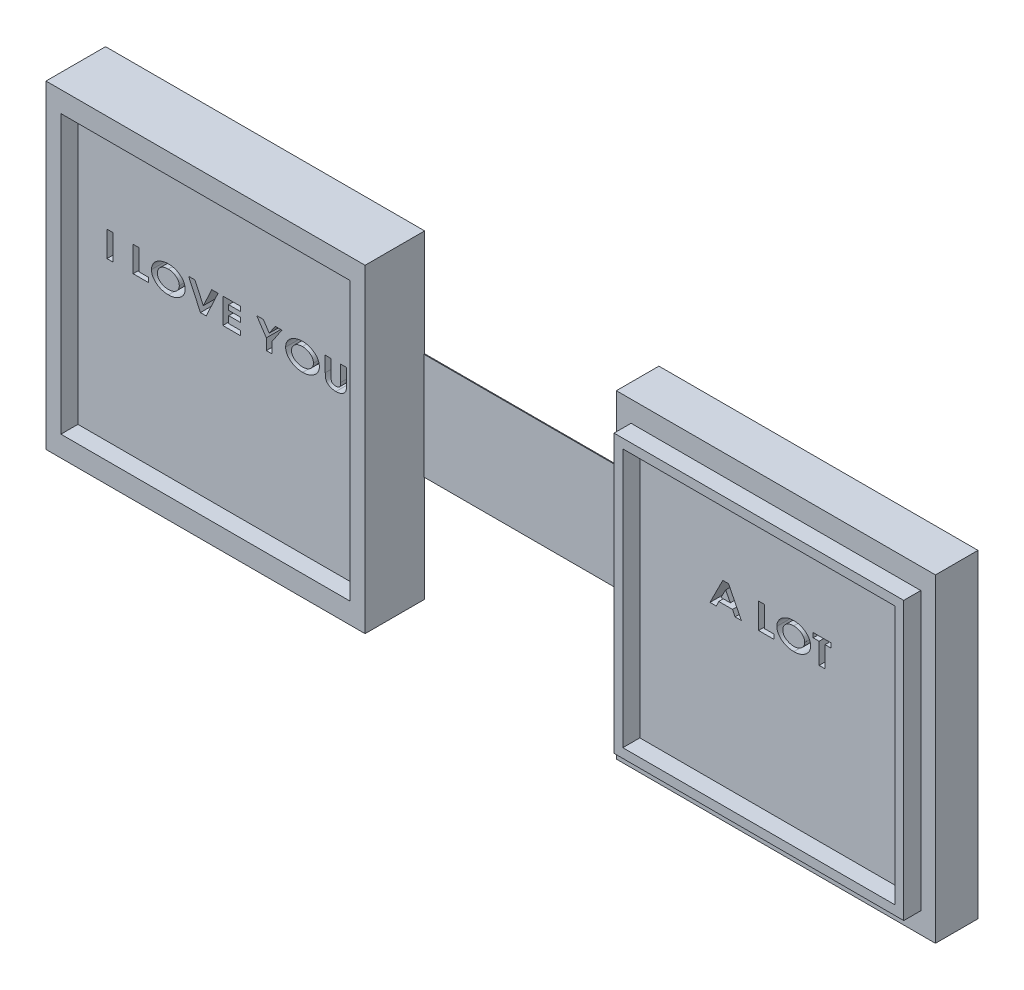
from build123d import *

# Parameters (mm, degrees)
BOSS_EXTRUDE1_DEPTH   = 10
BOSS_EXTRUDE1_2_DEPTH = 10
SKETCH2_3_W           = 55.063291139
SKETCH2_3_H           = 25
BOSS_EXTRUDE2_DEPTH   = 0.2
BOSS_EXTRUDE3_DEPTH   = 4
BOSS_EXTRUDE4_DEPTH   = 4
SKETCH8_W             = 1.384615385
SKETCH8_H             = 6
CUT_EXTRUDE2_DEPTH    = 7


with BuildPart() as part:
    # Sketch2 → Boss-Extrude1 (new body)
    with BuildSketch(Plane.XY):
        Polygon((-12.49990942, -20.310872493), (-12.49990942, -45.310872493), (-87.49990942, -45.310872493), (-87.49990942, 29.689127507), (-12.49990942, 29.689127507), (-12.49990942, 4.689127507), align=None)
    extrude(amount=BOSS_EXTRUDE1_DEPTH)



with BuildPart() as body_2:
    # Sketch2 → Boss-Extrude1 2 (new body)
    with BuildSketch(Plane.XY):
        Polygon((42.563381719, 4.689127507), (42.563381719, -20.310872493), (42.563381719, -45.310872493), (117.563381719, -45.310872493), (117.563381719, 29.689127507), (42.563381719, 29.689127507), align=None)
    extrude(amount=BOSS_EXTRUDE1_2_DEPTH)


with BuildPart() as part_1:
    add(part.part)

    add(body_2.part)  # Boss-Extrude2 merges body 2
    # Sketch2_3 → Boss-Extrude2 (add)
    with BuildSketch(Plane.XY):
        with Locations((15.03173615, -7.810872493)):
            Rectangle(SKETCH2_3_W, SKETCH2_3_H)
    extrude(amount=BOSS_EXTRUDE2_DEPTH)

    # Sketch5 → Boss-Extrude3 (add)
    with BuildSketch(Plane.XY.offset(10)):
        Polygon((-83.991546919, 24.821747046), (-16.008271922, 24.821747046), (-12.49990942, 29.689127507), (-87.49990942, 29.689127507), align=None)
        Polygon((-16.008271922, 24.821747046), (-16.008271922, -40.443492031), (-12.49990942, -45.310872493), (-12.49990942, 29.689127507), align=None)
        Polygon((-16.008271922, -40.443492031), (-12.49990942, -45.310872493), (-87.49990942, -45.310872493), (-87.49990942, 29.689127507), (-83.991546919, 24.821747046), (-83.991546919, -40.443492031), align=None)
    extrude(amount=BOSS_EXTRUDE3_DEPTH)

    # Sketch6 → Boss-Extrude4 (add)
    with BuildSketch(Plane.XY.offset(10)):
        Polygon((114.10947308, 24.782956382), (112.046327266, 22.605014842), (48.080436172, 22.605014842), (46.017290358, 24.782956382), align=None)
        Polygon((114.10947308, -40.404701367), (112.046327266, -38.226759827), (112.046327266, 22.605014842), (114.10947308, 24.782956382), align=None)
        Polygon((46.017290358, -40.404701367), (114.10947308, -40.404701367), (112.046327266, -38.226759827), (48.080436172, -38.226759827), (48.080436172, 22.605014842), (46.017290358, 24.782956382), align=None)
    extrude(amount=BOSS_EXTRUDE4_DEPTH)

    # Sketch8 → Cut-Extrude2 (cut)
    with BuildSketch(Plane.XY.offset(10)):
        with Locations((-76.480051234, -0.292779357)):
            Rectangle(SKETCH8_W, SKETCH8_H)
        Polygon((-71.018512773, 2.707220643), (-69.633897389, 2.707220643), (-69.633897389, -2.21585628), (-67.403128158, -2.21585628), (-67.403128158, -3.292779357), (-71.018512773, -3.292779357), align=None)
        with BuildLine():
            add(Edge.make_bspline(
                [(-62.733657004, 2.861066797), (-62.600922093, 2.858406668), (-62.339935127, 2.85317625), (-61.955697879, 2.808562096), (-61.585428768, 2.736832123), (-61.228959719, 2.636061047), (-60.887086087, 2.505697363), (-60.559861681, 2.346100222), (-60.246421792, 2.158141413), (-59.999306765, 1.978433493), (-59.811863981, 1.8233402), (-59.679959104, 1.703376976), (-59.556214435, 1.580379342), (-59.443142799, 1.45325819), (-59.336986998, 1.324393321), (-59.242733923, 1.190620751), (-59.156024227, 1.054708376), (-59.076830549, 0.916145229), (-59.009279244, 0.773509087), (-58.949170347, 0.628227538), (-58.900683399, 0.479253805), (-58.859472962, 0.327272656), (-58.826907017, 0.172430625), (-58.804045187, 0.014274117), (-58.79077044, -0.147117298), (-58.788758948, -0.25589632), (-58.787743542, -0.310808203)],
                knots=[0, 0, 0, 0, 1.701621513, 3.345774183, 4.952818867, 6.533559192, 8.08973942, 9.638370861, 11.196102205, 12.770417818, 13.551212677, 14.314953304, 15.05603302, 15.787307124, 16.495794601, 17.195736741, 17.884100935, 18.562753464, 19.240627723, 19.906540461, 20.577507338, 21.247982325, 21.925077417, 22.605128591, 23.295865934, 24, 24, 24, 24], degree=3))
            add(Edge.make_bspline(
                [(-58.787743542, -0.310808203), (-58.78877522, -0.3649174), (-58.790826313, -0.472492723), (-58.803962694, -0.632303529), (-58.827194238, -0.789112534), (-58.858314866, -0.942823265), (-58.897736737, -1.093549743), (-58.947390433, -1.24081721), (-59.006344314, -1.384765866), (-59.07374232, -1.525643336), (-59.149870345, -1.66336771), (-59.235026036, -1.798068499), (-59.330694622, -1.928989316), (-59.433842993, -2.057615845), (-59.545811508, -2.183171807), (-59.667901241, -2.304159607), (-59.797479712, -2.423721553), (-59.982938286, -2.576388055), (-60.227755411, -2.753496139), (-60.5387143, -2.939618947), (-60.865839219, -3.095776156), (-61.207332529, -3.22531263), (-61.564595072, -3.325061823), (-61.937313099, -3.395568523), (-62.325204993, -3.43833209), (-62.588916502, -3.44383229), (-62.722839696, -3.446625511)],
                knots=[0, 0, 0, 0, 0.697386028, 1.386483854, 2.064877695, 2.739310107, 3.406868283, 4.071444263, 4.740737576, 5.410508757, 6.083060732, 6.767791916, 7.46289943, 8.171737429, 8.892141444, 9.629680956, 10.386190422, 11.163678676, 12.724354505, 14.275829196, 15.827827946, 17.390074696, 18.977437917, 20.601801155, 22.274259438, 24, 24, 24, 24], degree=3))
            add(Edge.make_bspline(
                [(-62.722839696, -3.446625511), (-62.862798511, -3.444113121), (-63.13783885, -3.439175895), (-63.540667989, -3.39273309), (-63.926411388, -3.322594957), (-64.292606603, -3.217784133), (-64.642076275, -3.087462333), (-64.972558186, -2.925370831), (-65.285270981, -2.734813458), (-65.529021878, -2.552791621), (-65.712036458, -2.395668565), (-65.840423925, -2.274184025), (-65.960844737, -2.150738619), (-66.072013386, -2.023978012), (-66.173921474, -1.894112561), (-66.268131122, -1.762206586), (-66.352118182, -1.626962047), (-66.428692789, -1.489912998), (-66.494354874, -1.348948167), (-66.552194047, -1.205747145), (-66.601912407, -1.060278811), (-66.641347618, -0.911575844), (-66.672991427, -0.760395679), (-66.694090269, -0.606143935), (-66.707898909, -0.449279737), (-66.70984024, -0.343690253), (-66.710820466, -0.290375511)],
                knots=[0, 0, 0, 0, 1.784004293, 3.505839534, 5.164104166, 6.778110649, 8.356058462, 9.914283128, 11.464219954, 13.019326122, 13.787338316, 14.539035367, 15.272437815, 15.985633446, 16.68776482, 17.376668663, 18.051409406, 18.716821711, 19.377293231, 20.032826539, 20.685506957, 21.336104687, 21.993367612, 22.653720573, 23.320230207, 24, 24, 24, 24], degree=3))
            add(Edge.make_bspline(
                [(-66.710820466, -0.290375511), (-66.709248595, -0.219381645), (-66.706121498, -0.078145662), (-66.679620908, 0.131148243), (-66.639379845, 0.336327408), (-66.581010038, 0.536824964), (-66.506618956, 0.733155715), (-66.414204528, 0.924655488), (-66.30752088, 1.112854932), (-66.183044911, 1.29483208), (-66.046179778, 1.471426129), (-65.893255335, 1.636720747), (-65.731154375, 1.795892196), (-65.554008476, 1.942637687), (-65.365570498, 2.081728276), (-65.165213763, 2.211603084), (-64.951349596, 2.330261099), (-64.72759824, 2.440336532), (-64.495740751, 2.54027601), (-64.256810071, 2.624878227), (-64.014178327, 2.699309744), (-63.766118226, 2.75699729), (-63.514528187, 2.805212202), (-63.257885046, 2.836304814), (-62.997264161, 2.858347384), (-62.821845581, 2.86015703), (-62.733657004, 2.861066797)],
                knots=[0, 0, 0, 0, 0.908646913, 1.807672237, 2.696971879, 3.583367145, 4.47793267, 5.381919862, 6.30320595, 7.245054832, 8.2024345, 9.160995254, 10.125930706, 11.10912711, 12.103275238, 13.123444517, 14.16375238, 15.23278865, 16.315180442, 17.394163501, 18.476555293, 19.562732787, 20.653322387, 21.754667852, 22.871199116, 24, 24, 24, 24], degree=3))
        make_face()
        with BuildLine():
            add(Edge.make_bspline(
                [(-62.754089696, 1.78414372), (-62.843108459, 1.782289357), (-63.017977885, 1.778646627), (-63.274695453, 1.750198317), (-63.520924047, 1.705324302), (-63.756004226, 1.639929692), (-63.980201447, 1.557233185), (-64.19348302, 1.455522029), (-64.395648993, 1.334939374), (-64.58572423, 1.197650172), (-64.759109305, 1.046663287), (-64.911078665, 0.883385075), (-65.03866924, 0.709606685), (-65.145120706, 0.526906627), (-65.225919007, 0.33271736), (-65.283244487, 0.128917807), (-65.319443572, -0.08477018), (-65.323922926, -0.230534263), (-65.326205081, -0.304798587)],
                knots=[0, 0, 0, 0, 1.156256363, 2.271362584, 3.351443693, 4.404613939, 5.437209731, 6.452274934, 7.469899128, 8.491270218, 9.494550198, 10.452182295, 11.382870607, 12.289942592, 13.192808459, 14.107242739, 15.035672325, 16, 16, 16, 16], degree=3))
            add(Edge.make_bspline(
                [(-65.326205081, -0.304798587), (-65.323676838, -0.387153105), (-65.318704955, -0.549106294), (-65.272304421, -0.784471469), (-65.200711175, -1.007395612), (-65.096808237, -1.216343499), (-64.963709904, -1.411609939), (-64.801681021, -1.593593644), (-64.610645817, -1.761865085), (-64.466428702, -1.858500103), (-64.39231085, -1.908163972)],
                knots=[0, 0, 0, 0, 1.015643436, 1.997300182, 2.949804991, 3.898707565, 4.867193511, 5.85870606, 6.899519615, 8, 8, 8, 8], degree=3))
            add(Edge.make_bspline(
                [(-64.39231085, -1.908163972), (-64.331143374, -1.945173034), (-64.209243503, -2.018927916), (-64.016908463, -2.112552676), (-63.818426435, -2.191950643), (-63.613183416, -2.257155964), (-63.401054158, -2.307668696), (-63.182141524, -2.343356789), (-62.956877701, -2.3656782), (-62.804622424, -2.368351105), (-62.727647389, -2.369702434)],
                knots=[0, 0, 0, 0, 0.979445747, 1.951924769, 2.927746611, 3.907192357, 4.900758842, 5.913620849, 6.945198403, 8, 8, 8, 8], degree=3))
            add(Edge.make_bspline(
                [(-62.727647389, -2.369702434), (-62.64063873, -2.367809157), (-62.469778703, -2.364091306), (-62.218460569, -2.336168585), (-61.977075188, -2.288841246), (-61.744970841, -2.224932564), (-61.523140565, -2.139705866), (-61.311342521, -2.036089743), (-61.108801936, -1.914581606), (-60.918770675, -1.775570542), (-60.744064818, -1.623974866), (-60.592334455, -1.459602246), (-60.461814056, -1.288019626), (-60.35546461, -1.106987262), (-60.272524688, -0.916609078), (-60.215561395, -0.717277011), (-60.179137548, -0.5096509), (-60.174643261, -0.368253752), (-60.172358927, -0.296385126)],
                knots=[0, 0, 0, 0, 1.14206298, 2.242683837, 3.314374117, 4.368419416, 5.39889757, 6.429147533, 7.460108749, 8.495247058, 9.51643591, 10.491510393, 11.42663233, 12.341282468, 13.241130158, 14.144903984, 15.057101202, 16, 16, 16, 16], degree=3))
            add(Edge.make_bspline(
                [(-60.172358927, -0.296385126), (-60.174712507, -0.22493402), (-60.179355783, -0.083971193), (-60.214949834, 0.123212172), (-60.274447295, 0.32147036), (-60.356225856, 0.512281184), (-60.464909178, 0.692533443), (-60.5941443, 0.866036146), (-60.748206751, 1.029934578), (-60.92396985, 1.183144687), (-61.115481673, 1.324004611), (-61.319808555, 1.446735346), (-61.533031105, 1.552633892), (-61.758176609, 1.636323704), (-61.992990136, 1.702324063), (-62.237601645, 1.750867821), (-62.492634328, 1.778457514), (-62.665883395, 1.782225384), (-62.754089696, 1.78414372)],
                knots=[0, 0, 0, 0, 0.931113683, 1.836954292, 2.730897662, 3.624474801, 4.535405159, 5.468187164, 6.440023927, 7.461466965, 8.503989252, 9.534934908, 10.564993831, 11.602940381, 12.66110933, 13.741711846, 14.85023771, 16, 16, 16, 16], degree=3))
        make_face(mode=Mode.SUBTRACT)
        Polygon((-57.980051235, 2.707220643), (-56.495676235, 2.707220643), (-54.518512773, -1.554798587), (-52.536541619, 2.707220643), (-51.056974312, 2.707220643), (-53.846637773, -3.292779357), (-55.195195466, -3.292779357), align=None)
        Polygon((-49.941589696, 2.707220643), (-45.787743542, 2.707220643), (-45.787743542, 1.630297566), (-48.556974312, 1.630297566), (-48.556974312, 0.476451413), (-45.787743542, 0.476451413), (-45.787743542, -0.600471664), (-48.556974312, -0.600471664), (-48.556974312, -2.21585628), (-45.787743542, -2.21585628), (-45.787743542, -3.292779357), (-49.941589696, -3.292779357), align=None)
        Polygon((-41.980051235, 2.707220643), (-40.418753158, 2.707220643), (-39.019714696, 0.609864874), (-37.619474312, 2.707220643), (-36.056974312, 2.707220643), (-38.326205081, -0.694221664), (-38.326205081, -3.292779357), (-39.710820466, -3.292779357), (-39.710820466, -0.694221664), align=None)
        with BuildLine():
            add(Edge.make_bspline(
                [(-31.195195466, 2.861066797), (-31.062460555, 2.858406668), (-30.801473588, 2.85317625), (-30.41723634, 2.808562096), (-30.046967229, 2.736832123), (-29.69049818, 2.636061047), (-29.348624549, 2.505697363), (-29.021400142, 2.346100222), (-28.707960253, 2.158141413), (-28.460845227, 1.978433493), (-28.273402442, 1.8233402), (-28.141497566, 1.703376976), (-28.017752896, 1.580379342), (-27.90468126, 1.45325819), (-27.79852546, 1.324393321), (-27.704272384, 1.190620751), (-27.617562688, 1.054708376), (-27.538369011, 0.916145229), (-27.470817706, 0.773509087), (-27.410708808, 0.628227538), (-27.36222186, 0.479253805), (-27.321011424, 0.327272656), (-27.288445478, 0.172430625), (-27.265583649, 0.014274117), (-27.252308902, -0.147117298), (-27.25029741, -0.25589632), (-27.249282004, -0.310808203)],
                knots=[0, 0, 0, 0, 1.701621513, 3.345774183, 4.952818867, 6.533559192, 8.08973942, 9.638370861, 11.196102205, 12.770417818, 13.551212677, 14.314953304, 15.05603302, 15.787307124, 16.495794601, 17.195736741, 17.884100935, 18.562753464, 19.240627723, 19.906540461, 20.577507338, 21.247982325, 21.925077417, 22.605128591, 23.295865934, 24, 24, 24, 24], degree=3))
            add(Edge.make_bspline(
                [(-27.249282004, -0.310808203), (-27.250313681, -0.3649174), (-27.252364774, -0.472492723), (-27.265501156, -0.632303529), (-27.288732699, -0.789112534), (-27.319853328, -0.942823265), (-27.359275198, -1.093549743), (-27.408928895, -1.24081721), (-27.467882776, -1.384765866), (-27.535280782, -1.525643336), (-27.611408807, -1.66336771), (-27.696564498, -1.798068499), (-27.792233083, -1.928989316), (-27.895381455, -2.057615845), (-28.007349969, -2.183171807), (-28.129439702, -2.304159607), (-28.259018173, -2.423721553), (-28.444476747, -2.576388055), (-28.689293873, -2.753496139), (-29.000252761, -2.939618947), (-29.32737768, -3.095776156), (-29.668870991, -3.22531263), (-30.026133534, -3.325061823), (-30.39885156, -3.395568523), (-30.786743455, -3.43833209), (-31.050454963, -3.44383229), (-31.184378158, -3.446625511)],
                knots=[0, 0, 0, 0, 0.697386028, 1.386483854, 2.064877695, 2.739310107, 3.406868283, 4.071444263, 4.740737576, 5.410508757, 6.083060732, 6.767791916, 7.46289943, 8.171737429, 8.892141444, 9.629680956, 10.386190422, 11.163678676, 12.724354505, 14.275829196, 15.827827946, 17.390074696, 18.977437917, 20.601801155, 22.274259438, 24, 24, 24, 24], degree=3))
            add(Edge.make_bspline(
                [(-31.184378158, -3.446625511), (-31.324336973, -3.444113121), (-31.599377312, -3.439175895), (-32.00220645, -3.39273309), (-32.38794985, -3.322594957), (-32.754145064, -3.217784133), (-33.103614737, -3.087462333), (-33.434096648, -2.925370831), (-33.746809443, -2.734813458), (-33.990560339, -2.552791621), (-34.17357492, -2.395668565), (-34.301962386, -2.274184025), (-34.422383198, -2.150738619), (-34.533551848, -2.023978012), (-34.635459935, -1.894112561), (-34.729669584, -1.762206586), (-34.813656643, -1.626962047), (-34.890231251, -1.489912998), (-34.955893336, -1.348948167), (-35.013732509, -1.205747145), (-35.063450869, -1.060278811), (-35.10288608, -0.911575844), (-35.134529889, -0.760395679), (-35.155628731, -0.606143935), (-35.16943737, -0.449279737), (-35.171378701, -0.343690253), (-35.172358927, -0.290375511)],
                knots=[0, 0, 0, 0, 1.784004293, 3.505839534, 5.164104166, 6.778110649, 8.356058462, 9.914283128, 11.464219954, 13.019326122, 13.787338316, 14.539035367, 15.272437815, 15.985633446, 16.68776482, 17.376668663, 18.051409406, 18.716821711, 19.377293231, 20.032826539, 20.685506957, 21.336104687, 21.993367612, 22.653720573, 23.320230207, 24, 24, 24, 24], degree=3))
            add(Edge.make_bspline(
                [(-35.172358927, -0.290375511), (-35.170787056, -0.219381645), (-35.167659959, -0.078145662), (-35.14115937, 0.131148243), (-35.100918307, 0.336327408), (-35.042548499, 0.536824964), (-34.968157417, 0.733155715), (-34.875742989, 0.924655488), (-34.769059342, 1.112854932), (-34.644583372, 1.29483208), (-34.50771824, 1.471426129), (-34.354793796, 1.636720747), (-34.192692837, 1.795892196), (-34.015546938, 1.942637687), (-33.827108959, 2.081728276), (-33.626752225, 2.211603084), (-33.412888057, 2.330261099), (-33.189136702, 2.440336532), (-32.957279213, 2.54027601), (-32.718348533, 2.624878227), (-32.475716788, 2.699309744), (-32.227656687, 2.75699729), (-31.976066648, 2.805212202), (-31.719423507, 2.836304814), (-31.458802623, 2.858347384), (-31.283384043, 2.86015703), (-31.195195466, 2.861066797)],
                knots=[0, 0, 0, 0, 0.908646913, 1.807672237, 2.696971879, 3.583367145, 4.47793267, 5.381919862, 6.30320595, 7.245054832, 8.2024345, 9.160995254, 10.125930706, 11.10912711, 12.103275238, 13.123444517, 14.16375238, 15.23278865, 16.315180442, 17.394163501, 18.476555293, 19.562732787, 20.653322387, 21.754667852, 22.871199116, 24, 24, 24, 24], degree=3))
        make_face()
        with BuildLine():
            add(Edge.make_bspline(
                [(-31.215628158, 1.78414372), (-31.304646921, 1.782289357), (-31.479516347, 1.778646627), (-31.736233915, 1.750198317), (-31.982462509, 1.705324302), (-32.217542688, 1.639929692), (-32.441739908, 1.557233185), (-32.655021481, 1.455522029), (-32.857187454, 1.334939374), (-33.047262692, 1.197650172), (-33.220647767, 1.046663287), (-33.372617127, 0.883385075), (-33.500207702, 0.709606685), (-33.606659168, 0.526906627), (-33.687457469, 0.33271736), (-33.744782948, 0.128917807), (-33.780982034, -0.08477018), (-33.785461388, -0.230534263), (-33.787743542, -0.304798587)],
                knots=[0, 0, 0, 0, 1.156256363, 2.271362584, 3.351443693, 4.404613939, 5.437209731, 6.452274934, 7.469899128, 8.491270218, 9.494550198, 10.452182295, 11.382870607, 12.289942592, 13.192808459, 14.107242739, 15.035672325, 16, 16, 16, 16], degree=3))
            add(Edge.make_bspline(
                [(-33.787743542, -0.304798587), (-33.7852153, -0.387153105), (-33.780243417, -0.549106294), (-33.733842883, -0.784471469), (-33.662249636, -1.007395612), (-33.558346698, -1.216343499), (-33.425248365, -1.411609939), (-33.263219483, -1.593593644), (-33.072184279, -1.761865085), (-32.927967163, -1.858500103), (-32.853849312, -1.908163972)],
                knots=[0, 0, 0, 0, 1.015643436, 1.997300182, 2.949804991, 3.898707565, 4.867193511, 5.85870606, 6.899519615, 8, 8, 8, 8], degree=3))
            add(Edge.make_bspline(
                [(-32.853849312, -1.908163972), (-32.792681836, -1.945173034), (-32.670781964, -2.018927916), (-32.478446925, -2.112552676), (-32.279964896, -2.191950643), (-32.074721878, -2.257155964), (-31.86259262, -2.307668696), (-31.643679986, -2.343356789), (-31.418416163, -2.3656782), (-31.266160886, -2.368351105), (-31.18918585, -2.369702434)],
                knots=[0, 0, 0, 0, 0.979445747, 1.951924769, 2.927746611, 3.907192357, 4.900758842, 5.913620849, 6.945198403, 8, 8, 8, 8], degree=3))
            add(Edge.make_bspline(
                [(-31.18918585, -2.369702434), (-31.102177192, -2.367809157), (-30.931317165, -2.364091306), (-30.67999903, -2.336168585), (-30.43861365, -2.288841246), (-30.206509303, -2.224932564), (-29.984679027, -2.139705866), (-29.772880982, -2.036089743), (-29.570340398, -1.914581606), (-29.380309137, -1.775570542), (-29.20560328, -1.623974866), (-29.053872916, -1.459602246), (-28.923352517, -1.288019626), (-28.817003072, -1.106987262), (-28.73406315, -0.916609078), (-28.677099857, -0.717277011), (-28.64067601, -0.5096509), (-28.636181722, -0.368253752), (-28.633897389, -0.296385126)],
                knots=[0, 0, 0, 0, 1.14206298, 2.242683837, 3.314374117, 4.368419416, 5.39889757, 6.429147533, 7.460108749, 8.495247058, 9.51643591, 10.491510393, 11.42663233, 12.341282468, 13.241130158, 14.144903984, 15.057101202, 16, 16, 16, 16], degree=3))
            add(Edge.make_bspline(
                [(-28.633897389, -0.296385126), (-28.636250968, -0.22493402), (-28.640894245, -0.083971193), (-28.676488295, 0.123212172), (-28.735985757, 0.32147036), (-28.817764318, 0.512281184), (-28.92644764, 0.692533443), (-29.055682762, 0.866036146), (-29.209745213, 1.029934578), (-29.385508311, 1.183144687), (-29.577020135, 1.324004611), (-29.781347016, 1.446735346), (-29.994569566, 1.552633892), (-30.21971507, 1.636323704), (-30.454528598, 1.702324063), (-30.699140106, 1.750867821), (-30.954172789, 1.778457514), (-31.127421857, 1.782225384), (-31.215628158, 1.78414372)],
                knots=[0, 0, 0, 0, 0.931113683, 1.836954292, 2.730897662, 3.624474801, 4.535405159, 5.468187164, 6.440023927, 7.461466965, 8.503989252, 9.534934908, 10.564993831, 11.602940381, 12.66110933, 13.741711846, 14.85023771, 16, 16, 16, 16], degree=3))
        make_face(mode=Mode.SUBTRACT)
        with BuildLine():
            Line((-25.864666619, 2.707220643), (-24.480051235, 2.707220643))
            Line((-24.480051235, 2.707220643), (-24.480051235, -1.196625511))
            add(Edge.make_bspline(
                [(-24.480051235, -1.196625511), (-24.480075186, -1.237102353), (-24.480121459, -1.315302119), (-24.473355653, -1.427485504), (-24.465548572, -1.530598626), (-24.45350417, -1.624453048), (-24.438453787, -1.709683815), (-24.418837461, -1.785331728), (-24.39836831, -1.852475941), (-24.362022202, -1.927741435), (-24.308740898, -2.013681728), (-24.222768586, -2.101415696), (-24.122897842, -2.181926273), (-24.003778811, -2.24896473), (-23.869383161, -2.302090584), (-23.721225167, -2.342558042), (-23.559630857, -2.364506312), (-23.447660667, -2.367934296), (-23.389907004, -2.369702434)],
                knots=[0, 0, 0, 0, 1.042330976, 2.013744964, 2.893880655, 3.705397848, 4.450270186, 5.121044372, 5.718245416, 6.253772157, 7.270030384, 8.30662409, 9.400940003, 10.565730178, 11.811328046, 13.115564187, 14.512222457, 16, 16, 16, 16], degree=3))
            add(Edge.make_bspline(
                [(-23.389907004, -2.369702434), (-23.328492666, -2.368355461), (-23.209855871, -2.365753454), (-23.038642302, -2.338147547), (-22.879903826, -2.295983188), (-22.73623565, -2.23431024), (-22.608972898, -2.160948701), (-22.501916586, -2.076402575), (-22.415001798, -1.982821057), (-22.361287673, -1.893266478), (-22.32738228, -1.812905281), (-22.306349162, -1.74024483), (-22.288354939, -1.655489511), (-22.274871293, -1.55861077), (-22.262381354, -1.44966023), (-22.254481172, -1.32853625), (-22.249611942, -1.195064782), (-22.249395077, -1.102079194), (-22.249282004, -1.053596664)],
                knots=[0, 0, 0, 0, 1.444790072, 2.790964898, 4.072527466, 5.302503052, 6.460906732, 7.521628549, 8.503271233, 9.451296571, 9.962868575, 10.553781864, 11.229096548, 12.001525687, 12.855738701, 13.810777885, 14.858543254, 16, 16, 16, 16], degree=3))
            Line((-22.249282004, -1.053596664), (-22.249282004, 2.707220643))
            Line((-22.249282004, 2.707220643), (-20.864666619, 2.707220643))
            Line((-20.864666619, 2.707220643), (-20.864666619, -0.87210628))
            add(Edge.make_bspline(
                [(-20.864666619, -0.87210628), (-20.865186359, -0.944626345), (-20.866185822, -1.084083085), (-20.872111529, -1.284456814), (-20.88168208, -1.467597987), (-20.894122807, -1.633256628), (-20.91224118, -1.781583844), (-20.933683475, -1.912735964), (-20.957717644, -2.027192939), (-20.998652111, -2.157110866), (-21.065195787, -2.30771102), (-21.173212559, -2.479045513), (-21.30755072, -2.64854747), (-21.469801561, -2.810195928), (-21.651299558, -2.961143488), (-21.848492084, -3.095317936), (-22.060728479, -3.205322985), (-22.286928381, -3.295353005), (-22.529004341, -3.363960238), (-22.789499783, -3.410796794), (-23.06824057, -3.441943488), (-23.260810971, -3.445035265), (-23.359858927, -3.446625511)],
                knots=[0, 0, 0, 0, 1.048465452, 2.016208535, 2.897852646, 3.699721694, 4.417449558, 5.057358133, 5.620907919, 6.10638888, 7.024441343, 7.992080414, 9.026953953, 10.145102751, 11.296847888, 12.435865683, 13.58618256, 14.745679343, 15.950263297, 17.216971339, 18.568558298, 20, 20, 20, 20], degree=3))
            add(Edge.make_bspline(
                [(-23.359858927, -3.446625511), (-23.425594674, -3.445760752), (-23.555224276, -3.444055464), (-23.746502352, -3.428796395), (-23.931569974, -3.40669073), (-24.109812289, -3.374269679), (-24.281519232, -3.331837643), (-24.44711058, -3.280657244), (-24.60589599, -3.219077444), (-24.757147316, -3.149488771), (-24.900090776, -3.072841721), (-25.032856921, -2.989829662), (-25.156298806, -2.904022518), (-25.267322967, -2.811200211), (-25.369878889, -2.716186514), (-25.460463898, -2.614506204), (-25.539951188, -2.508040095), (-25.611839816, -2.395735706), (-25.673128753, -2.270142955), (-25.723885028, -2.127150969), (-25.768488056, -1.965357825), (-25.803676997, -1.784065825), (-25.830834617, -1.583371229), (-25.851092706, -1.363640355), (-25.863043936, -1.124243523), (-25.86411217, -0.95825818), (-25.864666619, -0.87210628)],
                knots=[0, 0, 0, 0, 1.139223061, 2.246525513, 3.324074361, 4.368811041, 5.384430518, 6.388205074, 7.370907534, 8.334155974, 9.272474927, 10.180097188, 11.047120909, 11.875808385, 12.686403601, 13.468414007, 14.232299858, 14.987551083, 15.776407491, 16.648561, 17.613934854, 18.683036789, 19.846822431, 21.123122364, 22.506805041, 24, 24, 24, 24], degree=3))
            Line((-25.864666619, -0.87210628), (-25.864666619, 2.707220643))
        make_face()
        Polygon((67.576028761, 3.588799792), (68.925788377, 3.588799792), (71.943817223, -2.411200208), (70.459442223, -2.411200208), (69.866894146, -1.180430977), (66.634922992, -1.180430977), (66.043576838, -2.411200208), (64.559201838, -2.411200208), align=None)
        Polygon((68.251509531, 1.979424792), (67.152951838, -0.103507901), (69.350067223, -0.103507901), align=None, mode=Mode.SUBTRACT)
        Polygon((75.982278761, 3.588799792), (77.366894146, 3.588799792), (77.366894146, -1.334277131), (79.597663377, -1.334277131), (79.597663377, -2.411200208), (75.982278761, -2.411200208), align=None)
        with BuildLine():
            add(Edge.make_bspline(
                [(84.267134531, 3.742645946), (84.399869441, 3.739985816), (84.660856408, 3.734755398), (85.045093656, 3.690141244), (85.415362767, 3.618411271), (85.771831816, 3.517640195), (86.113705448, 3.387276511), (86.440929854, 3.227679371), (86.754369743, 3.039720562), (87.00148477, 2.860012641), (87.188927554, 2.704919348), (87.320832431, 2.584956124), (87.4445771, 2.461958491), (87.557648736, 2.334837338), (87.663804536, 2.205972469), (87.758057612, 2.0721999), (87.844767308, 1.936287524), (87.923960985, 1.797724378), (87.99151229, 1.655088236), (88.051621188, 1.509806686), (88.100108136, 1.360832953), (88.141318573, 1.208851804), (88.173884518, 1.054009773), (88.196746348, 0.895853265), (88.210021095, 0.73446185), (88.212032587, 0.625682828), (88.213047992, 0.570770946)],
                knots=[0, 0, 0, 0, 1.701621513, 3.345774183, 4.952818867, 6.533559192, 8.08973942, 9.638370861, 11.196102205, 12.770417818, 13.551212677, 14.314953304, 15.05603302, 15.787307124, 16.495794601, 17.195736741, 17.884100935, 18.562753464, 19.240627723, 19.906540461, 20.577507338, 21.247982325, 21.925077417, 22.605128591, 23.295865934, 24, 24, 24, 24], degree=3))
            add(Edge.make_bspline(
                [(88.213047992, 0.570770946), (88.212016315, 0.516661749), (88.209965222, 0.409086425), (88.196828841, 0.24927562), (88.173597297, 0.092466615), (88.142476669, -0.061244117), (88.103054798, -0.211970595), (88.053401102, -0.359238062), (87.994447221, -0.503186717), (87.927049215, -0.644064188), (87.850921189, -0.781788561), (87.765765498, -0.916489351), (87.670096913, -1.047410167), (87.566948541, -1.176036697), (87.454980027, -1.301592659), (87.332890294, -1.422580459), (87.203311823, -1.542142405), (87.017853249, -1.694808907), (86.773036123, -1.871916991), (86.462077235, -2.058039798), (86.134952316, -2.214197007), (85.793459005, -2.343733482), (85.436196463, -2.443482674), (85.063478436, -2.513989375), (84.675586541, -2.556752942), (84.411875033, -2.562253142), (84.277951838, -2.565046362)],
                knots=[0, 0, 0, 0, 0.697386028, 1.386483854, 2.064877695, 2.739310107, 3.406868283, 4.071444263, 4.740737576, 5.410508757, 6.083060732, 6.767791916, 7.46289943, 8.171737429, 8.892141444, 9.629680956, 10.386190422, 11.163678676, 12.724354505, 14.275829196, 15.827827946, 17.390074696, 18.977437917, 20.601801155, 22.274259438, 24, 24, 24, 24], degree=3))
            add(Edge.make_bspline(
                [(84.277951838, -2.565046362), (84.137993024, -2.562533973), (83.862952685, -2.557596746), (83.460123546, -2.511153941), (83.074380147, -2.441015809), (82.708184932, -2.336204985), (82.35871526, -2.205883184), (82.028233349, -2.043791682), (81.715520554, -1.85323431), (81.471769657, -1.671212472), (81.288755076, -1.514089416), (81.16036761, -1.392604876), (81.039946798, -1.269159471), (80.928778149, -1.142398864), (80.826870061, -1.012533412), (80.732660413, -0.880627437), (80.648673353, -0.745382899), (80.572098746, -0.608333849), (80.506436661, -0.467369018), (80.448597488, -0.324167997), (80.398879127, -0.178699663), (80.359443916, -0.029996695), (80.327800107, 0.121183469), (80.306701266, 0.275435214), (80.292892626, 0.432299412), (80.290951295, 0.537888895), (80.289971069, 0.591203638)],
                knots=[0, 0, 0, 0, 1.784004293, 3.505839534, 5.164104166, 6.778110649, 8.356058462, 9.914283128, 11.464219954, 13.019326122, 13.787338316, 14.539035367, 15.272437815, 15.985633446, 16.68776482, 17.376668663, 18.051409406, 18.716821711, 19.377293231, 20.032826539, 20.685506957, 21.336104687, 21.993367612, 22.653720573, 23.320230207, 24, 24, 24, 24], degree=3))
            add(Edge.make_bspline(
                [(80.289971069, 0.591203638), (80.29154294, 0.662197504), (80.294670037, 0.803433487), (80.321170627, 1.012727392), (80.36141169, 1.217906556), (80.419781497, 1.418404112), (80.494172579, 1.614734864), (80.586587007, 1.806234636), (80.693270655, 1.994434081), (80.817746624, 2.176411228), (80.954611757, 2.353005277), (81.1075362, 2.518299895), (81.26963716, 2.677471344), (81.446783059, 2.824216835), (81.635221037, 2.963307424), (81.835577771, 3.093182232), (82.049441939, 3.211840248), (82.273193295, 3.321915681), (82.505050783, 3.421855158), (82.743981464, 3.506457375), (82.986613208, 3.580888892), (83.234673309, 3.638576438), (83.486263348, 3.68679135), (83.742906489, 3.717883962), (84.003527374, 3.739926532), (84.178945953, 3.741736178), (84.267134531, 3.742645946)],
                knots=[0, 0, 0, 0, 0.908646913, 1.807672237, 2.696971879, 3.583367145, 4.47793267, 5.381919862, 6.30320595, 7.245054832, 8.2024345, 9.160995254, 10.125930706, 11.10912711, 12.103275238, 13.123444517, 14.16375238, 15.23278865, 16.315180442, 17.394163501, 18.476555293, 19.562732787, 20.653322387, 21.754667852, 22.871199116, 24, 24, 24, 24], degree=3))
        make_face()
        with BuildLine():
            add(Edge.make_bspline(
                [(84.246701838, 2.665722869), (84.157683076, 2.663868506), (83.98281365, 2.660225775), (83.726096082, 2.631777465), (83.479867487, 2.58690345), (83.244787309, 2.521508841), (83.020590088, 2.438812334), (82.807308515, 2.337101178), (82.605142542, 2.216518522), (82.415067304, 2.07922932), (82.24168223, 1.928242436), (82.089712869, 1.764964223), (81.962122294, 1.591185833), (81.855670829, 1.408485776), (81.774872528, 1.214296509), (81.717547048, 1.010496956), (81.681347963, 0.796808969), (81.676868609, 0.651044885), (81.674586454, 0.576780561)],
                knots=[0, 0, 0, 0, 1.156256363, 2.271362584, 3.351443693, 4.404613939, 5.437209731, 6.452274934, 7.469899128, 8.491270218, 9.494550198, 10.452182295, 11.382870607, 12.289942592, 13.192808459, 14.107242739, 15.035672325, 16, 16, 16, 16], degree=3))
            add(Edge.make_bspline(
                [(81.674586454, 0.576780561), (81.677114697, 0.494426043), (81.682086579, 0.332472855), (81.728487113, 0.097107679), (81.80008036, -0.125816463), (81.903983298, -0.33476435), (82.037081631, -0.530030791), (82.199110514, -0.712014495), (82.390145717, -0.880285936), (82.534362833, -0.976920954), (82.608480685, -1.026584824)],
                knots=[0, 0, 0, 0, 1.015643436, 1.997300182, 2.949804991, 3.898707565, 4.867193511, 5.85870606, 6.899519615, 8, 8, 8, 8], degree=3))
            add(Edge.make_bspline(
                [(82.608480685, -1.026584824), (82.66964816, -1.063593886), (82.791548032, -1.137348768), (82.983883071, -1.230973527), (83.1823651, -1.310371495), (83.387608118, -1.375576815), (83.599737377, -1.426089548), (83.81865001, -1.46177764), (84.043913834, -1.484099051), (84.196169111, -1.486771956), (84.273144146, -1.488123285)],
                knots=[0, 0, 0, 0, 0.979445747, 1.951924769, 2.927746611, 3.907192357, 4.900758842, 5.913620849, 6.945198403, 8, 8, 8, 8], degree=3))
            add(Edge.make_bspline(
                [(84.273144146, -1.488123285), (84.360152804, -1.486230009), (84.531012832, -1.482512157), (84.782330966, -1.454589436), (85.023716346, -1.407262098), (85.255820694, -1.343353415), (85.477650969, -1.258126717), (85.689449014, -1.154510595), (85.891989598, -1.033002457), (86.082020859, -0.893991394), (86.256726717, -0.742395717), (86.40845708, -0.578023098), (86.538977479, -0.406440477), (86.645326925, -0.225408113), (86.728266846, -0.03502993), (86.78523014, 0.164302137), (86.821653986, 0.371928249), (86.826148274, 0.513325397), (86.828432608, 0.585194023)],
                knots=[0, 0, 0, 0, 1.14206298, 2.242683837, 3.314374117, 4.368419416, 5.39889757, 6.429147533, 7.460108749, 8.495247058, 9.51643591, 10.491510393, 11.42663233, 12.341282468, 13.241130158, 14.144903984, 15.057101202, 16, 16, 16, 16], degree=3))
            add(Edge.make_bspline(
                [(86.828432608, 0.585194023), (86.826079028, 0.656645129), (86.821435752, 0.797607955), (86.785841701, 1.00479132), (86.726344239, 1.203049508), (86.644565678, 1.393860332), (86.535882356, 1.574112592), (86.406647234, 1.747615295), (86.252584783, 1.911513726), (86.076821685, 2.064723836), (85.885309862, 2.205583759), (85.68098298, 2.328314494), (85.46776043, 2.434213041), (85.242614926, 2.517902852), (85.007801399, 2.583903211), (84.76318989, 2.632446969), (84.508157207, 2.660036663), (84.334908139, 2.663804533), (84.246701838, 2.665722869)],
                knots=[0, 0, 0, 0, 0.931113683, 1.836954292, 2.730897662, 3.624474801, 4.535405159, 5.468187164, 6.440023927, 7.461466965, 8.503989252, 9.534934908, 10.564993831, 11.602940381, 12.66110933, 13.741711846, 14.85023771, 16, 16, 16, 16], degree=3))
        make_face(mode=Mode.SUBTRACT)
        Polygon((88.828432608, 3.588799792), (92.982278761, 3.588799792), (92.982278761, 2.511876715), (91.597663377, 2.511876715), (91.597663377, -2.411200208), (90.213047992, -2.411200208), (90.213047992, 2.511876715), (88.828432608, 2.511876715), align=None)
    extrude(amount=-CUT_EXTRUDE2_DEPTH, mode=Mode.SUBTRACT)


solid = part_1.part
